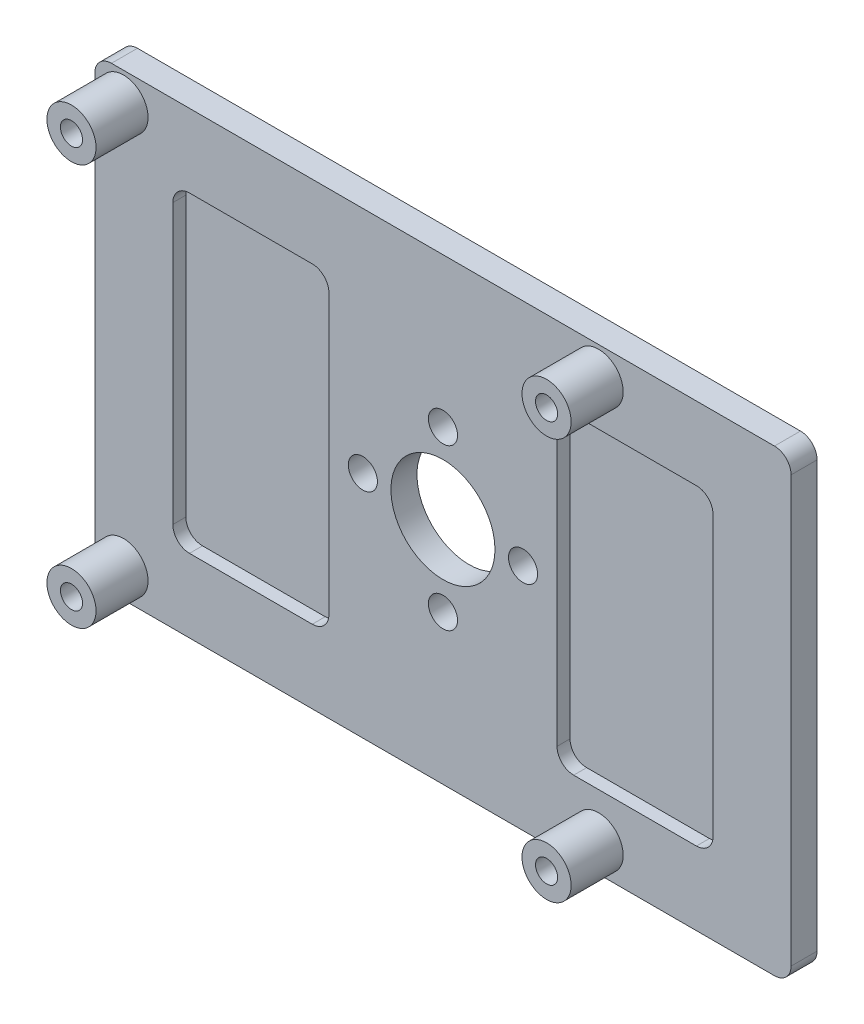
from build123d import *

# Parameters (mm, degrees)
SKETCH1_W               = 85
SKETCH1_H               = 56
BOSS_EXTRUDE1_DEPTH     = 3.175
SKETCH2_R               = 6.35
CUT_EXTRUDE1_DEPTH      = 3.175
SKETCH3_R               = 1.778
CUT_EXTRUDE2_DEPTH      = 3.175
CIRPATTERN1_COUNT       = 4
SKETCH4_R               = 3
BOSS_EXTRUDE2_DEPTH     = 6.35
SKETCH6_R               = 1.349999967
CUT_EXTRUDE3_DEPTH      = 7.35
CUT_EXTRUDE3_DEPTH_BACK = 4.175
SKETCH7_R               = 2.159
CUT_EXTRUDE4_DEPTH      = 7.025
SKETCH8_W               = 19.05
SKETCH8_H               = 38.1
CUT_EXTRUDE5_DEPTH      = 1.5875
FILLET1_R               = 2.032


with BuildPart() as part:
    # Sketch1 → Boss-Extrude1 (new body)
    with BuildSketch(Plane.XY):
        with Locations((42.5, 28)):
            Rectangle(SKETCH1_W, SKETCH1_H)
    extrude(amount=BOSS_EXTRUDE1_DEPTH)

    # Sketch2 → Cut-Extrude1 (cut)
    with BuildSketch(Plane.XY.offset(3.175)):
        with Locations((42.5, 28)):
            Circle(SKETCH2_R)
    extrude(amount=-CUT_EXTRUDE1_DEPTH, mode=Mode.SUBTRACT)

    # Sketch3 → Cut-Extrude2 (cut)
    with BuildSketch(Plane.XY.offset(3.175)):
        with Locations((42.5, 37.779)):
            Circle(SKETCH3_R)
    cut_extrude2 = extrude(amount=-CUT_EXTRUDE2_DEPTH, mode=Mode.SUBTRACT)

    # CirPattern1: Cut-Extrude2 ×4 about axis
    cirpattern1_axis = Axis((42.5, 28, 0), (0, 0, 1))
    for i in range(1, CIRPATTERN1_COUNT):
        add(cut_extrude2.rotate(cirpattern1_axis, i * 360 / CIRPATTERN1_COUNT), mode=Mode.SUBTRACT)

    # Sketch4 → Boss-Extrude2 (add)
    with BuildSketch(Plane.XY.offset(3.175)):
        with Locations((3.5, 52.5)):
            Circle(SKETCH4_R)
        with Locations((3.5, 3.5)):
            Circle(SKETCH4_R)
        with Locations((61.5, 52.5)):
            Circle(SKETCH4_R)
        with Locations((61.5, 3.5)):
            Circle(SKETCH4_R)
    extrude(amount=BOSS_EXTRUDE2_DEPTH)

    # Sketch6 → Cut-Extrude3 (cut, two sides)
    with BuildSketch(Plane.XY.offset(3.175)) as cut_extrude3_sk:
        with Locations((3.5, 3.5)):
            Circle(SKETCH6_R)
        with Locations((61.5, 3.5)):
            Circle(SKETCH6_R)
        with Locations((61.5, 52.5)):
            Circle(SKETCH6_R)
        with Locations((3.5, 52.5)):
            Circle(SKETCH6_R)
    extrude(amount=CUT_EXTRUDE3_DEPTH, mode=Mode.SUBTRACT)
    extrude(cut_extrude3_sk.sketch, amount=-CUT_EXTRUDE3_DEPTH_BACK, mode=Mode.SUBTRACT)

    # Sketch7 → Cut-Extrude4 (cut)
    with BuildSketch(Plane(origin=(0, 0, 0), x_dir=(-1, 0, 0), z_dir=(0, 0, -1))):
        with Locations((-61.5, 52.5)):
            Circle(SKETCH7_R)
        with Locations((-3.5, 52.5)):
            Circle(SKETCH7_R)
        with Locations((-3.5, 3.5)):
            Circle(SKETCH7_R)
        with Locations((-61.5, 3.5)):
            Circle(SKETCH7_R)
    extrude(amount=-CUT_EXTRUDE4_DEPTH, mode=Mode.SUBTRACT)

    # Sketch8 → Cut-Extrude5 (cut)
    with BuildSketch(Plane.XY.offset(3.175)):
        with Locations((19.05, 28)):
            Rectangle(SKETCH8_W, SKETCH8_H)
        with Locations((65.95, 28)):
            Rectangle(SKETCH8_W, SKETCH8_H)
    extrude(amount=-CUT_EXTRUDE5_DEPTH, mode=Mode.SUBTRACT)

    # Fillet1
    fillet1_edges = [part.edges().sort_by_distance(p)[0] for p in [
        (9.525, 8.95, 2.38125),
        (9.525, 47.05, 2.38125),
        (28.575, 47.05, 2.38125),
        (28.575, 8.95, 2.38125),
        (56.425, 8.95, 2.38125),
        (56.425, 47.05, 2.38125),
        (75.475, 47.05, 2.38125),
        (75.475, 8.95, 2.38125),
        (0, 56, 1.5875),
        (85, 56, 1.5875),
        (85, 0, 1.5875),
        (0, 0, 1.5875),
    ]]
    fillet(fillet1_edges, radius=FILLET1_R)


solid = part.part
